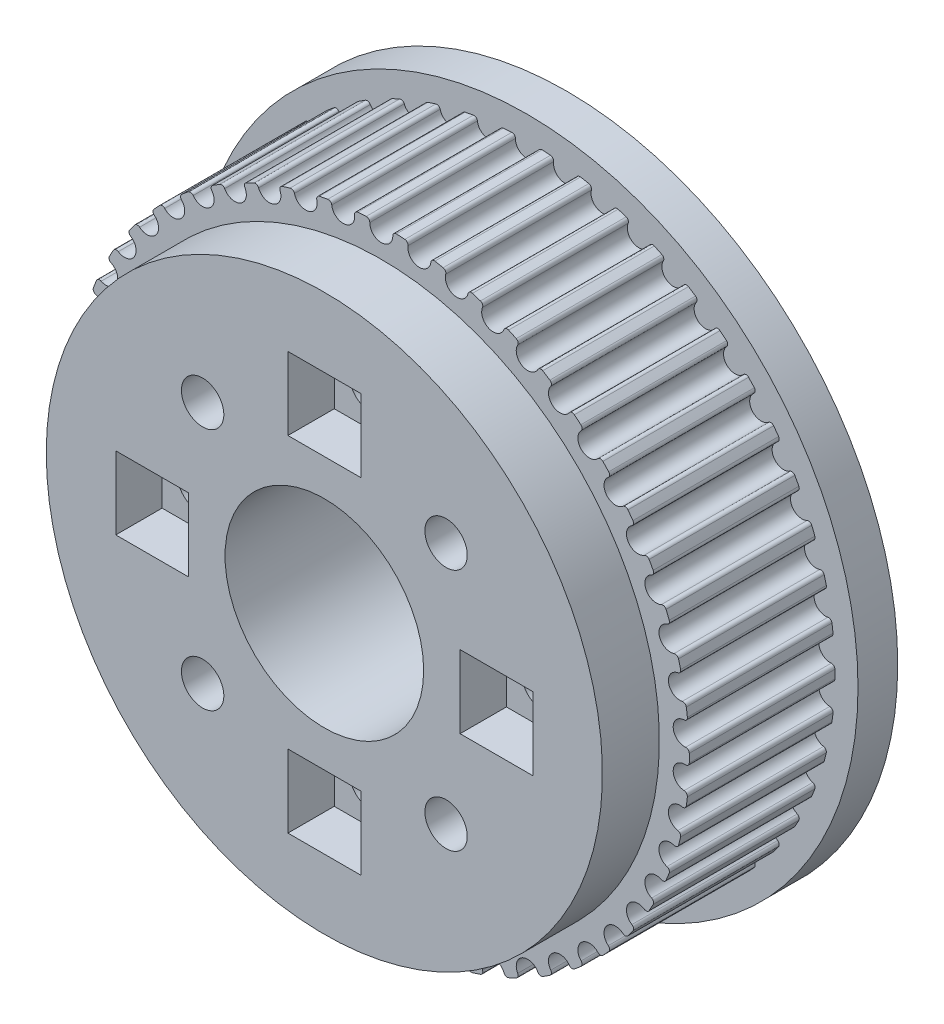
from build123d import *

# Parameters (mm, degrees)
BOSS_EXTRUDE1_START      = 3
BOSS_EXTRUDE1_DEPTH      = 11
FILLET1_R                = 0.26
CIRPATTERN1_COUNT        = 50
FILLET1_OF_CIRPATTERN1_R = 0.26
SKETCH2_R                = 25
SKETCH2_R_2              = 21
BOSS_EXTRUDE2_DEPTH      = 3
BOSS_EXTRUDE3_START      = 14
SKETCH2_3_R              = 21
BOSS_EXTRUDE3_DEPTH      = 4.3
SKETCH3_R                = 1.6
CUT_EXTRUDE1_DEPTH       = 40.810677085
CUT_EXTRUDE1_DEPTH_BACK  = 40.810677085
SKETCH3_3_W              = 5.5
SKETCH3_3_H              = 5.5
SKETCH3_3_R              = 1.6
CUT_EXTRUDE2_DEPTH       = 40.810677085
CUT_EXTRUDE2_DEPTH_BACK  = 3.5
SKETCH4_R                = 1.6
CUT_EXTRUDE3_DEPTH       = 40.810677085
SKETCH4_3_W              = 5.5
SKETCH4_3_H              = 5.5
SKETCH4_3_R              = 1.6
CUT_EXTRUDE4_DEPTH       = 3
SKETCH5_R                = 7.5
CUT_EXTRUDE5_DEPTH       = 40.810677085


with BuildPart() as part:
    # Sketch1 → Boss-Extrude1 (new body)
    with BuildSketch(Plane(origin=(0, 0, 0), x_dir=(0, 1, 0), z_dir=(0, 0, 1)).offset(BOSS_EXTRUDE1_START)):
        with BuildLine():
            Line((0, 0), (0, 23.258241464))
            ThreePointArc((0, 23.258241464), (0.319668882, 23.256044543), (0.639277374, 23.249454196))
            ThreePointArc((0.639277374, 23.249454196), (1.386932157, 22.044655365), (2.279692792, 23.146248006))
            ThreePointArc((2.279692792, 23.146248006), (2.597607065, 23.11272882), (2.91503061, 23.074843283))
            Line((2.91503061, 23.074843283), (0, 0))
        make_face()
    boss_extrude1 = extrude(amount=BOSS_EXTRUDE1_DEPTH)

    # Fillet1
    fillet1_edges = [part.edges().sort_by_distance(p)[0] for p in [
        (-23.249454196, 0.639277374, 8.5),
        (-23.146248006, 2.279692792, 8.5),
    ]]
    fillet(fillet1_edges, radius=FILLET1_R)

    # CirPattern1: Boss-Extrude1 ×50 about axis
    cirpattern1_axis = Axis((0, 0, 0), (0, 0, 1))
    for i in range(1, CIRPATTERN1_COUNT):
        add(boss_extrude1.rotate(cirpattern1_axis, i * 360 / CIRPATTERN1_COUNT))

    # Fillet1 of CirPattern1
    fillet1_of_cirpattern1_edges = [part.edges().sort_by_distance(p)[0] for p in [
        (-23.146248006, -2.279692792, 8.5),
        (-23.249454196, -0.639277374, 8.5),
        (-22.678011658, -5.162710841, 8.5),
        (-22.986002605, -3.548165754, 8.5),
        (-21.852129519, -7.964309856, 8.5),
        (-22.360048022, -6.40109744, 8.5),
        (-20.681626243, -10.640306947, 8.5),
        (-21.381462124, -9.153079997, 8.5),
        (-19.184961367, -13.148500041, 8.5),
        (-20.065677796, -11.760713013, 8.5),
        (-17.38573819, -15.449333435, 8.5),
        (-18.433445742, -14.18287256, 8.5),
        (-15.312331536, -17.506521611, 8.5),
        (-16.510507238, -16.381359734, 8.5),
        (-12.997440266, -19.287621484, 8.5),
        (-14.327188171, -18.32150308, 8.5),
        (-10.477571599, -20.764544044, 8.5),
        (-11.917920788, -19.972705377, 8.5),
        (-7.792465369, -21.913997341, 8.5),
        (-9.320700675, -21.308926179, 8.5),
        (-4.984467305, -22.717853809, 8.5),
        (-6.576487544, -22.309092486, 8.5),
        (-2.097861214, -23.163436151, 8.5),
        (-3.728559277, -22.957431078, 8.5),
        (0.821829402, -23.243717268, 8.5),
        (-0.821829402, -23.243717268, 8.5),
        (3.728559277, -22.957431078, 8.5),
        (2.097861214, -23.163436151, 8.5),
        (6.576487544, -22.309092486, 8.5),
        (4.984467305, -22.717853809, 8.5),
        (9.320700675, -21.308926179, 8.5),
        (7.792465369, -21.913997341, 8.5),
        (11.917920788, -19.972705377, 8.5),
        (10.477571599, -20.764544044, 8.5),
        (14.327188171, -18.32150308, 8.5),
        (12.997440266, -19.287621484, 8.5),
        (16.510507238, -16.381359734, 8.5),
        (15.312331536, -17.506521611, 8.5),
        (18.433445742, -14.18287256, 8.5),
        (17.38573819, -15.449333435, 8.5),
        (20.065677796, -11.760713013, 8.5),
        (19.184961367, -13.148500041, 8.5),
        (21.381462124, -9.153079997, 8.5),
        (20.681626243, -10.640306947, 8.5),
        (22.360048022, -6.40109744, 8.5),
        (21.852129519, -7.964309856, 8.5),
        (22.986002605, -3.548165754, 8.5),
        (22.678011658, -5.162710841, 8.5),
        (23.249454196, -0.639277374, 8.5),
        (23.146248006, -2.279692792, 8.5),
        (23.146248006, 2.279692792, 8.5),
        (23.249454196, 0.639277374, 8.5),
        (22.678011658, 5.162710841, 8.5),
        (22.986002605, 3.548165754, 8.5),
        (21.852129519, 7.964309856, 8.5),
        (22.360048022, 6.40109744, 8.5),
        (20.681626243, 10.640306947, 8.5),
        (21.381462124, 9.153079997, 8.5),
        (19.184961367, 13.148500041, 8.5),
        (20.065677796, 11.760713013, 8.5),
        (17.38573819, 15.449333435, 8.5),
        (18.433445742, 14.18287256, 8.5),
        (15.312331536, 17.506521611, 8.5),
        (16.510507238, 16.381359734, 8.5),
        (12.997440266, 19.287621484, 8.5),
        (14.327188171, 18.32150308, 8.5),
        (10.477571599, 20.764544044, 8.5),
        (11.917920788, 19.972705377, 8.5),
        (7.792465369, 21.913997341, 8.5),
        (9.320700675, 21.308926179, 8.5),
        (4.984467305, 22.717853809, 8.5),
        (6.576487544, 22.309092486, 8.5),
        (2.097861214, 23.163436151, 8.5),
        (3.728559277, 22.957431078, 8.5),
        (-0.821829402, 23.243717268, 8.5),
        (0.821829402, 23.243717268, 8.5),
        (-3.728559277, 22.957431078, 8.5),
        (-2.097861214, 23.163436151, 8.5),
        (-6.576487544, 22.309092486, 8.5),
        (-4.984467305, 22.717853809, 8.5),
        (-9.320700675, 21.308926179, 8.5),
        (-7.792465369, 21.913997341, 8.5),
        (-11.917920788, 19.972705377, 8.5),
        (-10.477571599, 20.764544044, 8.5),
        (-14.327188171, 18.32150308, 8.5),
        (-12.997440266, 19.287621484, 8.5),
        (-16.510507238, 16.381359734, 8.5),
        (-15.312331536, 17.506521611, 8.5),
        (-18.433445742, 14.18287256, 8.5),
        (-17.38573819, 15.449333435, 8.5),
        (-20.065677796, 11.760713013, 8.5),
        (-19.184961367, 13.148500041, 8.5),
        (-21.381462124, 9.153079997, 8.5),
        (-20.681626243, 10.640306947, 8.5),
        (-22.360048022, 6.40109744, 8.5),
        (-21.852129519, 7.964309856, 8.5),
        (-22.986002605, 3.548165754, 8.5),
        (-22.678011658, 5.162710841, 8.5),
    ]]
    fillet(fillet1_of_cirpattern1_edges, radius=FILLET1_OF_CIRPATTERN1_R)

    # Sketch2 → Boss-Extrude2 (add)
    with BuildSketch(Plane(origin=(0, 0, 0), x_dir=(0, 1, 0), z_dir=(0, 0, 1))):
        with Locations(Location((0, 0, 0), (0, 0, 90))):
            Circle(SKETCH2_R)
        Circle(SKETCH2_R_2, mode=Mode.SUBTRACT)
        Circle(SKETCH2_R_2)
    extrude(amount=BOSS_EXTRUDE2_DEPTH)

    # Sketch2_3 → Boss-Extrude3 (add)
    with BuildSketch(Plane(origin=(0, 0, 0), x_dir=(0, 1, 0), z_dir=(0, 0, 1)).offset(BOSS_EXTRUDE3_START)):
        with Locations(Location((0, 0, 0), (0, 0, 90))):
            Circle(SKETCH2_3_R)
    extrude(amount=BOSS_EXTRUDE3_DEPTH)

    # Sketch3 → Cut-Extrude1 (cut, two sides)
    with BuildSketch(Plane.XY.offset(18.3)) as cut_extrude1_sk:
        with Locations((0, 13)):
            Circle(SKETCH3_R)
        with Locations((13, 0)):
            Circle(SKETCH3_R)
        with Locations((0, -13)):
            Circle(SKETCH3_R)
        with Locations((-13, 0)):
            Circle(SKETCH3_R)
    extrude(amount=CUT_EXTRUDE1_DEPTH, mode=Mode.SUBTRACT)
    extrude(cut_extrude1_sk.sketch, amount=-CUT_EXTRUDE1_DEPTH_BACK, mode=Mode.SUBTRACT)

    # Sketch3_3 → Cut-Extrude2 (cut, two sides)
    with BuildSketch(Plane.XY.offset(18.3)) as cut_extrude2_sk:
        with Locations((-13, 0)):
            Rectangle(SKETCH3_3_W, SKETCH3_3_H)
        with Locations((-13, 0)):
            Circle(SKETCH3_3_R, mode=Mode.SUBTRACT)
        with Locations((-13, 0)):
            Circle(SKETCH3_3_R)
        with Locations((0, 13)):
            Rectangle(SKETCH3_3_W, SKETCH3_3_H)
        with Locations((0, 13)):
            Circle(SKETCH3_3_R, mode=Mode.SUBTRACT)
        with Locations((0, 13)):
            Circle(SKETCH3_3_R)
        with Locations((13, 0)):
            Rectangle(SKETCH3_3_W, SKETCH3_3_H)
        with Locations((13, 0)):
            Circle(SKETCH3_3_R, mode=Mode.SUBTRACT)
        with Locations((0, -13)):
            Rectangle(SKETCH3_3_W, SKETCH3_3_H)
        with Locations((0, -13)):
            Circle(SKETCH3_3_R, mode=Mode.SUBTRACT)
        with Locations((0, -13)):
            Circle(SKETCH3_3_R)
        with Locations((13, 0)):
            Circle(SKETCH3_3_R)
    extrude(amount=CUT_EXTRUDE2_DEPTH, mode=Mode.SUBTRACT)
    extrude(cut_extrude2_sk.sketch, amount=-CUT_EXTRUDE2_DEPTH_BACK, mode=Mode.SUBTRACT)

    # Sketch4 → Cut-Extrude3 (cut, through all)
    with BuildSketch(Plane(origin=(0, 0, 0), x_dir=(1, 0, 0), z_dir=(0, 0, -1))):
        with Locations(Location((-9.192388155, 9.192388155, 0), (0, 0, 180))):
            Circle(SKETCH4_R)
        with Locations(Location((9.192388155, 9.192388155, 0), (0, 0, 180))):
            Circle(SKETCH4_R)
        with Locations(Location((9.192388155, -9.192388155, 0), (0, 0, 180))):
            Circle(SKETCH4_R)
        with Locations(Location((-9.192388155, -9.192388155, 0), (0, 0, 180))):
            Circle(SKETCH4_R)
    extrude(amount=-CUT_EXTRUDE3_DEPTH, mode=Mode.SUBTRACT)

    # Sketch4_3 → Cut-Extrude4 (cut)
    with BuildSketch(Plane(origin=(0, 0, 0), x_dir=(1, 0, 0), z_dir=(0, 0, -1))):
        with Locations((9.192388155, -9.192388155)):
            Rectangle(SKETCH4_3_W, SKETCH4_3_H)
        with Locations(Location((9.192388155, -9.192388155, 0), (0, 0, 180))):
            Circle(SKETCH4_3_R, mode=Mode.SUBTRACT)
        with Locations((9.192388155, 9.192388155)):
            Rectangle(SKETCH4_3_W, SKETCH4_3_H)
        with Locations(Location((9.192388155, 9.192388155, 0), (0, 0, 180))):
            Circle(SKETCH4_3_R, mode=Mode.SUBTRACT)
        with Locations((-9.192388155, -9.192388155)):
            Rectangle(SKETCH4_3_W, SKETCH4_3_H)
        with Locations(Location((-9.192388155, -9.192388155, 0), (0, 0, 180))):
            Circle(SKETCH4_3_R, mode=Mode.SUBTRACT)
        with Locations((-9.192388155, 9.192388155)):
            Rectangle(SKETCH4_3_W, SKETCH4_3_H)
        with Locations(Location((-9.192388155, 9.192388155, 0), (0, 0, 180))):
            Circle(SKETCH4_3_R, mode=Mode.SUBTRACT)
    extrude(amount=-CUT_EXTRUDE4_DEPTH, mode=Mode.SUBTRACT)

    # Sketch5 → Cut-Extrude5 (cut, through all)
    with BuildSketch(Plane.XY.offset(18.3)):
        Circle(SKETCH5_R)
    extrude(amount=-CUT_EXTRUDE5_DEPTH, mode=Mode.SUBTRACT)


solid = part.part
